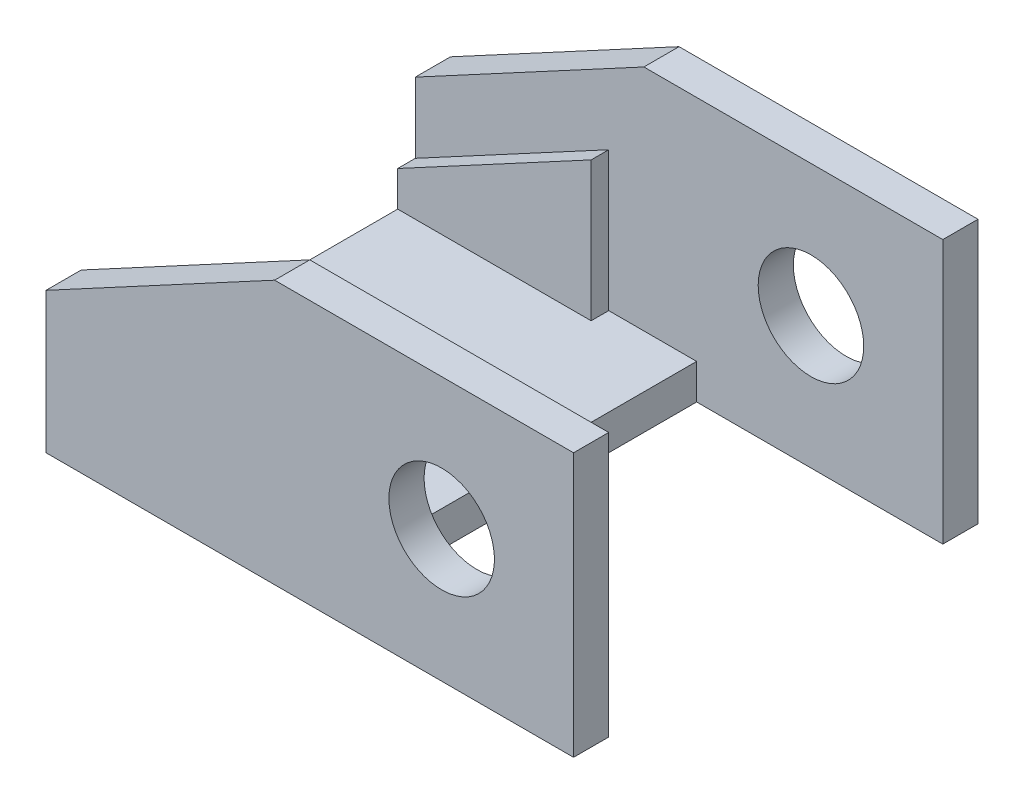
from build123d import *

# Parameters (mm, degrees)
ESQUISSE2_W                  = 16
ESQUISSE2_H                  = 9.5
BOSS_EXTRU_1_DEPTH           = 2
ESQUISSE5_W                  = 16
ESQUISSE5_H                  = 2
BOSS_EXTRU_2_DEPTH           = 15
ENL_V_MAT_EXTRU_1_DEPTH      = 1
ENL_V_MAT_EXTRU_1_DEPTH_BACK = 12.5
ESQUISSE7_W                  = 2
ESQUISSE7_H                  = 15
BOSS_EXTRU_3_DEPTH           = 14
BOSS_EXTRU_4_DEPTH           = 1
ENL_V_MAT_EXTRU_2_REACH      = 13.5
ESQUISSE9_R                  = 3
ENL_V_MAT_EXTRU_3_REACH      = 4
ESQUISSE11_R                 = 1.5
CHANFREIN1_SIZE              = 1
CHANFREIN1_SIZE2             = 1.732050808


with BuildPart() as part:
    # Esquisse2 → Boss.-Extru.1 (new body)
    with BuildSketch(Plane(origin=(0, 0, 0), x_dir=(1, 0, 0), z_dir=(0, 1, 0))):
        with Locations((0, 4.75)):
            Rectangle(ESQUISSE2_W, ESQUISSE2_H)
    extrude(amount=BOSS_EXTRU_1_DEPTH)

    # Esquisse5 → Boss.-Extru.2 (add)
    with BuildSketch(Plane.XZ):
        with Locations((0, -10.5)):
            Rectangle(ESQUISSE5_W, ESQUISSE5_H)
    extrude(amount=-BOSS_EXTRU_2_DEPTH)

    # Esquisse6 → Enlèv. mat.-Extru.1 (cut, two sides)
    with BuildSketch(Plane(origin=(0, 0, -11.5), x_dir=(-1, 0, 0), z_dir=(0, 0, -1))) as enl_v_mat_extru_1_sk:
        Polygon((-48.758415637, 38.562223804), (-5, 15), (8, 8), (51.758415637, -15.562223804), (98.882863246, 71.954607469), (-1.633968028, 126.079055078), align=None)
    extrude(amount=ENL_V_MAT_EXTRU_1_DEPTH, mode=Mode.SUBTRACT)
    extrude(enl_v_mat_extru_1_sk.sketch, amount=-ENL_V_MAT_EXTRU_1_DEPTH_BACK, mode=Mode.SUBTRACT)

    # Esquisse7 → Boss.-Extru.3 (add)
    with BuildSketch(Plane(origin=(8, 0, 0), x_dir=(0, 0, -1), z_dir=(1, 0, 0))):
        with Locations((10.5, 7.5)):
            Rectangle(ESQUISSE7_W, ESQUISSE7_H)
    extrude(amount=BOSS_EXTRU_3_DEPTH)

    # Esquisse8 → Boss.-Extru.4 (add)
    with BuildSketch(Plane.XY.offset(-9.5)):
        Polygon((-8, 2), (-8, 4), (3, 9.923076923), (3, 2), align=None)
    extrude(amount=BOSS_EXTRU_4_DEPTH)

    # Esquisse9 → Enlèv. mat.-Extru.2 (cut, up to next)
    with BuildSketch(Plane(origin=(0, 0, -11.5), x_dir=(-1, 0, 0), z_dir=(0, 0, -1)), mode=Mode.PRIVATE) as enl_v_mat_extru_2_sk1:
        with Locations((-14.5, 7.5)):
            Circle(ESQUISSE9_R)
    enl_v_mat_extru_2_tool1 = extrude(enl_v_mat_extru_2_sk1.sketch, amount=-ENL_V_MAT_EXTRU_2_REACH, mode=Mode.PRIVATE) & part.part
    add(enl_v_mat_extru_2_tool1.solids().sort_by_distance((14.5, 7.5, -11.5))[0], mode=Mode.SUBTRACT)

    # Symétrie1: part across plane


with BuildPart() as part_1:
    add(part.part)
    add(part.part.mirror(Plane(origin=(-8, 2, 0), x_dir=(1, 0, 0), z_dir=(0, 0, -1))))

    # Esquisse11 → Enlèv. mat.-Extru.3 (cut, up to next)
    with BuildSketch(Plane(origin=(0, 2, 0), x_dir=(1, 0, 0), z_dir=(0, 1, 0)), mode=Mode.PRIVATE) as enl_v_mat_extru_3_sk1:
        with Locations((-4, 0)):
            Circle(ESQUISSE11_R)
    enl_v_mat_extru_3_tool1 = extrude(enl_v_mat_extru_3_sk1.sketch, amount=-ENL_V_MAT_EXTRU_3_REACH, mode=Mode.PRIVATE) & part_1.part
    add(enl_v_mat_extru_3_tool1.solids().sort_by_distance((-4, 2, 0))[0], mode=Mode.SUBTRACT)
    # Esquisse11 → Enlèv. mat.-Extru.3 (cut, up to next)
    with BuildSketch(Plane(origin=(0, 2, 0), x_dir=(1, 0, 0), z_dir=(0, 1, 0)), mode=Mode.PRIVATE) as enl_v_mat_extru_3_sk2:
        with Locations((4, 0)):
            Circle(ESQUISSE11_R)
    enl_v_mat_extru_3_tool2 = extrude(enl_v_mat_extru_3_sk2.sketch, amount=-ENL_V_MAT_EXTRU_3_REACH, mode=Mode.PRIVATE) & part_1.part
    add(enl_v_mat_extru_3_tool2.solids().sort_by_distance((4, 2, 0))[0], mode=Mode.SUBTRACT)

    # Chanfrein1
    chanfrein1_edges = [part_1.edges().sort_by_distance(p)[0] for p in [
        (-5.5, 2, 0),
        (2.5, 2, 0),
    ]]
    chanfrein1_side = [part_1.faces().sort_by_distance(p)[0] for p in [
        (0.205328971, 2, 0),
    ]]
    chamfer(chanfrein1_edges, length=CHANFREIN1_SIZE, length2=CHANFREIN1_SIZE2, reference=chanfrein1_side[0])


solid = part_1.part
